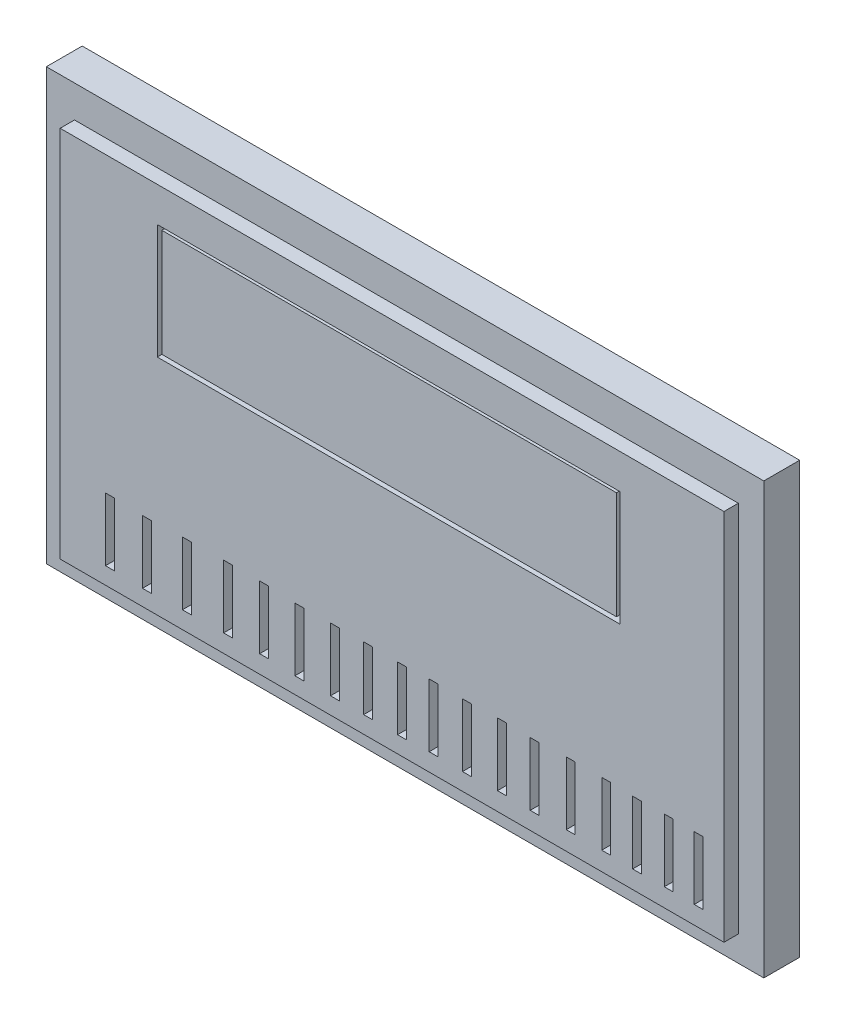
from build123d import *

# Parameters (mm, degrees)
SKETCH2_W           = 100
SKETCH2_H           = 60
BOSS_EXTRUDE1_DEPTH = 5
SKETCH3_W           = 92.52
SKETCH3_H           = 52
BOSS_EXTRUDE2_DEPTH = 2
SKETCH4_W           = 64.5
SKETCH4_H           = 16
CUT_EXTRUDE1_DEPTH  = 14
SKETCH5_W           = 1.24119343
SKETCH5_H           = 8.791786798
SKETCH5_W_2         = 1.241193431
SKETCH5_H_2         = 8.791786797
CUT_EXTRUDE2_DEPTH  = 14
SKETCH6_W           = 1.24119343
SKETCH6_H           = 8.791786798
SKETCH6_W_2         = 1.241193431
CUT_EXTRUDE3_DEPTH  = 14
SKETCH7_W           = 63.376055327
SKETCH7_H           = 14.974633453
BOSS_EXTRUDE8_DEPTH = 7


with BuildPart() as part:
    # Sketch2 → Boss-Extrude1 (new body)
    with BuildSketch(Plane.XY):
        with Locations((20.212765957, -7.021276596)):
            Rectangle(SKETCH2_W, SKETCH2_H)
    extrude(amount=BOSS_EXTRUDE1_DEPTH)

    # Sketch3 → Boss-Extrude2 (add)
    with BuildSketch(Plane.XY.offset(5)):
        with Locations((20.40011256, -7.487292221)):
            Rectangle(SKETCH3_W, SKETCH3_H)
    extrude(amount=BOSS_EXTRUDE2_DEPTH)

    # Sketch4 → Cut-Extrude1 (cut)
    with BuildSketch(Plane(origin=(0, 0, 0), x_dir=(-1, 0, 0), z_dir=(0, 0, -1))):
        with Locations((-19.923496788, 5.665280576)):
            Rectangle(SKETCH4_W, SKETCH4_H)
    extrude(amount=-CUT_EXTRUDE1_DEPTH, mode=Mode.SUBTRACT)

    # Sketch5 → Cut-Extrude2 (cut)
    with BuildSketch(Plane(origin=(0, 0, 0), x_dir=(-1, 0, 0), z_dir=(0, 0, -1))):
        with Locations((-58.967669826, -26.54783239)):
            Rectangle(SKETCH5_W, SKETCH5_H)
        with Locations((-63.137372089, -26.593640335)):
            Rectangle(SKETCH5_W_2, SKETCH5_H)
        with Locations((-54.549798109, -26.606737346)):
            Rectangle(SKETCH5_W_2, SKETCH5_H)
        with Locations((-50.249736303, -26.488927434)):
            Rectangle(SKETCH5_W, SKETCH5_H_2)
        with Locations((-45.301719979, -26.488927434)):
            Rectangle(SKETCH5_W, SKETCH5_H_2)
        with Locations((-40.275732606, -26.667494155)):
            Rectangle(SKETCH5_W, SKETCH5_H)
        with Locations((-35.712038447, -26.572417194)):
            Rectangle(SKETCH5_W, SKETCH5_H)
        with Locations((-30.835918022, -26.705630403)):
            Rectangle(SKETCH5_W_2, SKETCH5_H)
        with Locations((-26.193864427, -26.635405439)):
            Rectangle(SKETCH5_W, SKETCH5_H_2)
        with Locations((-21.787346613, -26.781075449)):
            Rectangle(SKETCH5_W, SKETCH5_H)
        with Locations((-17.061367018, -26.720926789)):
            Rectangle(SKETCH5_W_2, SKETCH5_H)
        with Locations((-12.443116631, -26.755913534)):
            Rectangle(SKETCH5_W_2, SKETCH5_H)
        with Locations((-7.47499879, -26.825887025)):
            Rectangle(SKETCH5_W, SKETCH5_H)
        with Locations((-2.567689738, -26.615966553)):
            Rectangle(SKETCH5_W_2, SKETCH5_H)
        with Locations((2.461236892, -26.615966553)):
            Rectangle(SKETCH5_W, SKETCH5_H)
        with Locations((8.200133962, -26.695073308)):
            Rectangle(SKETCH5_W_2, SKETCH5_H)
    extrude(amount=-CUT_EXTRUDE2_DEPTH, mode=Mode.SUBTRACT)

    # Sketch6 → Cut-Extrude3 (cut)
    with BuildSketch(Plane(origin=(0, 0, 0), x_dir=(-1, 0, 0), z_dir=(0, 0, -1))):
        with Locations((13.767615527, -26.890005841)):
            Rectangle(SKETCH6_W, SKETCH6_H)
        with Locations((18.928169849, -26.738087529)):
            Rectangle(SKETCH6_W_2, SKETCH6_H)
    extrude(amount=-CUT_EXTRUDE3_DEPTH, mode=Mode.SUBTRACT)


with BuildPart() as body_2:
    # Sketch7 → Boss-Extrude8 (new body)
    with BuildSketch(Plane(origin=(0, 0, 0), x_dir=(-1, 0, 0), z_dir=(0, 0, -1))):
        with Locations((-19.990265658, 5.79720755)):
            Rectangle(SKETCH7_W, SKETCH7_H)
    extrude(amount=-BOSS_EXTRUDE8_DEPTH)


solid = Compound([part.part, body_2.part])
